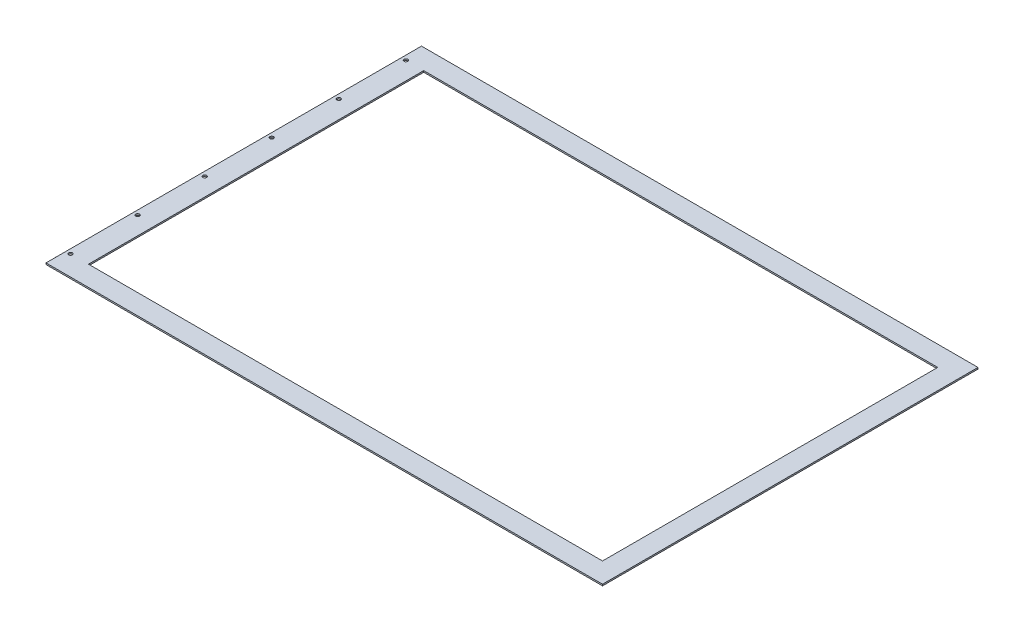
from build123d import *

# Parameters (mm, degrees)
SKETCH1_W                   = 876.3
SKETCH1_H                   = 571.5
BOSS_EXTRUDE1_DEPTH         = 2.54
F_1_4_0_25_DIAMETER_HOLE1_D = 6.35
LPATTERN1_COUNT             = 6
LPATTERN1_PITCH             = 114.3


with BuildPart() as part:
    # Sketch1 → Boss-Extrude1 (new body)
    with BuildSketch(Plane(origin=(0, 0, 0), x_dir=(1, 0, 0), z_dir=(0, 1, 0))):
        Polygon((-472.44, -320.04), (472.44, -320.04), (472.44, 320.04), (-472.44, 320.04), (-476.25, 320.04), (-476.25, -320.04), align=None)
        Rectangle(SKETCH1_W, SKETCH1_H, mode=Mode.SUBTRACT)
    extrude(amount=BOSS_EXTRUDE1_DEPTH)

    # 1/4 (0.25) Diameter Hole1 (through all)
    with Locations(Plane(origin=(-468.63, 2.54, -285.75), x_dir=(0, 0, 1), z_dir=(0, 1, 0))):
        with Locations((0, 0)):
            f_1_4_0_25_diameter_hole1 = Hole(F_1_4_0_25_DIAMETER_HOLE1_D / 2)

    # LPattern1: 1/4 (0.25) Diameter Hole1 ×6
    with Locations(*[(0, 0, i * LPATTERN1_PITCH) for i in range(1, LPATTERN1_COUNT)]):
        add(f_1_4_0_25_diameter_hole1, mode=Mode.SUBTRACT)


solid = part.part
